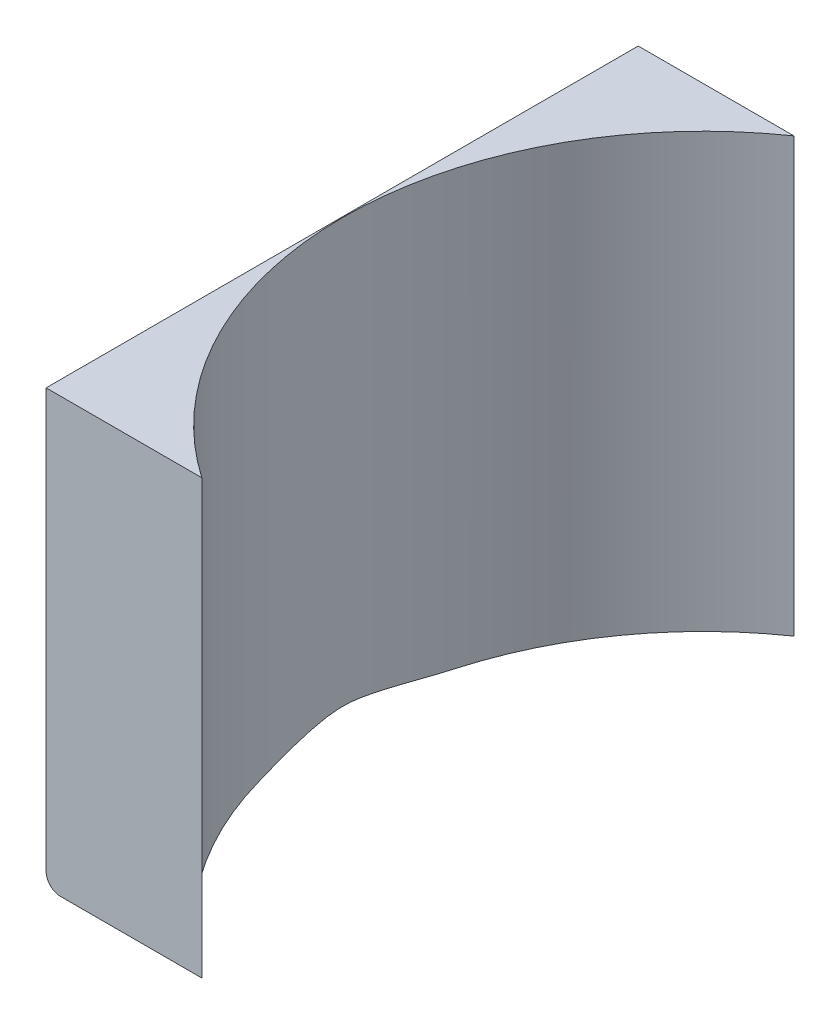
from build123d import *

# Parameters (mm, degrees)
SKETCH_1_W          = 25
SKETCH_1_H          = 41
EXTRUDE_1_DEPTH     = 30
FILLET_1_R          = 1
SKETCH_2_R          = 24.95
CUT_EXTRUDE_1_DEPTH = 30


with BuildPart() as part:
    # Эскиз1 → Бобышка-Вытянуть1 (new body)
    with BuildSketch(Plane(origin=(0, 0, 0), x_dir=(1, 0, 0), z_dir=(0, 1, 0))):
        Rectangle(SKETCH_1_W, SKETCH_1_H)
    extrude(amount=EXTRUDE_1_DEPTH)

    # Скругление1
    fillet_1_edges = [part.edges().sort_by_distance(p)[0] for p in [
        (-12.5, 0, 0),
    ]]
    fillet(fillet_1_edges, radius=FILLET_1_R)

    # Эскиз2 → Вырез-Вытянуть1 (cut)
    with BuildSketch(Plane(origin=(0, 30, 0), x_dir=(1, 0, 0), z_dir=(0, 1, 0))):
        with Locations((12.5, 0)):
            Circle(SKETCH_2_R)
    extrude(amount=-CUT_EXTRUDE_1_DEPTH, mode=Mode.SUBTRACT)


solid = part.part
